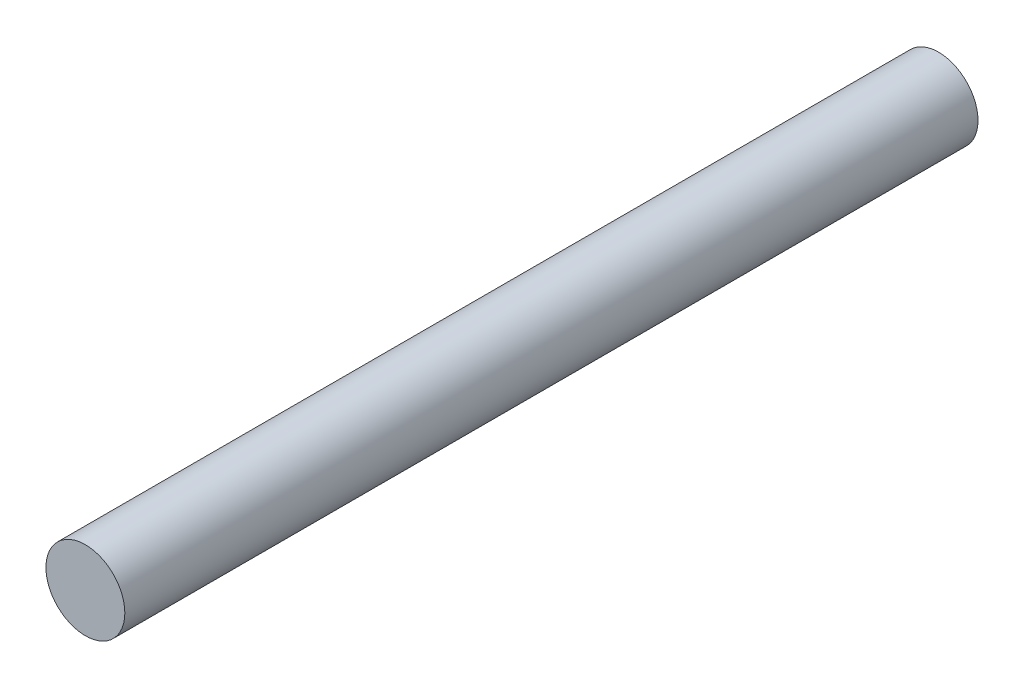
from build123d import *

# Parameters (mm, degrees)
SKETCH1_R           = 4.624813963
BOSS_EXTRUDE1_DEPTH = 100


with BuildPart() as part:
    # Sketch1 → Boss-Extrude1 (new body)
    with BuildSketch(Plane.XY):
        Circle(SKETCH1_R)
    extrude(amount=BOSS_EXTRUDE1_DEPTH)


solid = part.part
